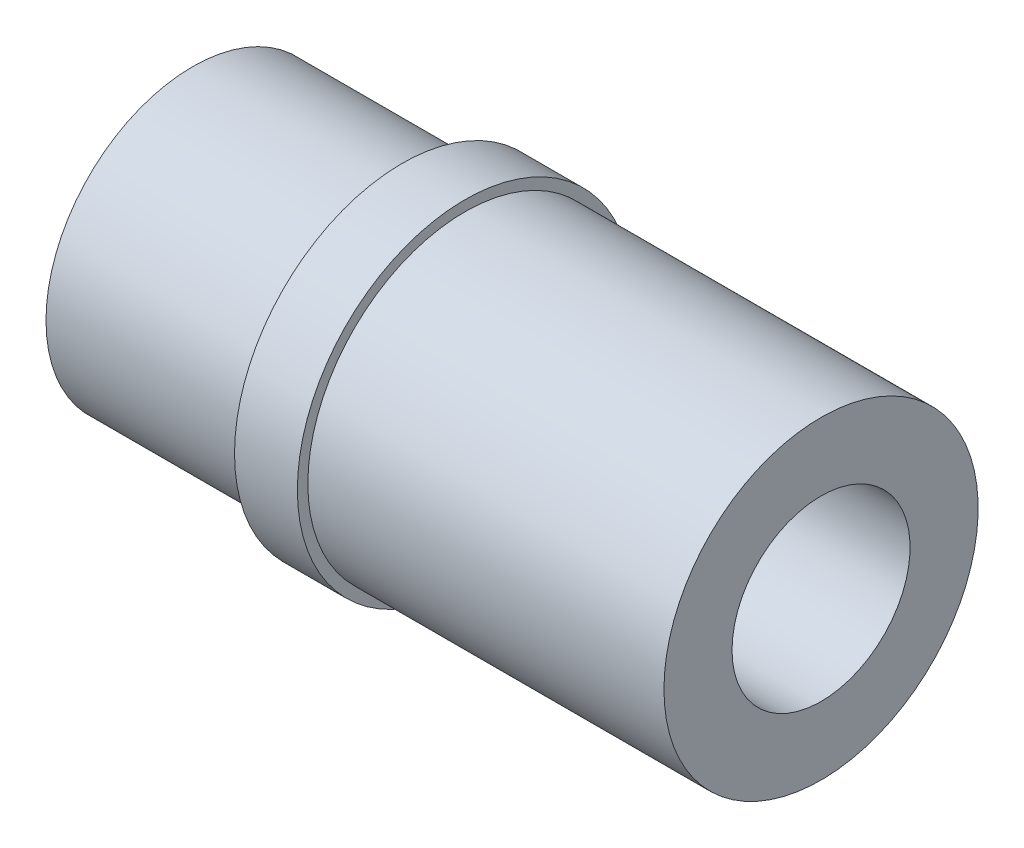
from build123d import *


with BuildPart() as part:
    # Sketch1 → Revolve1 (revolve)
    with BuildSketch(Plane.XY):
        Polygon((0, 4.25), (-21.105787847, 4.25), (-30, 5.5), (-30, 7), (-20, 7), (-20, 8), (-17, 8), (-17, 7.5), (0, 7.5), align=None)
    revolve(axis=Axis((-108.783752644, 0, 0), (1, 0, 0)))


solid = part.part
